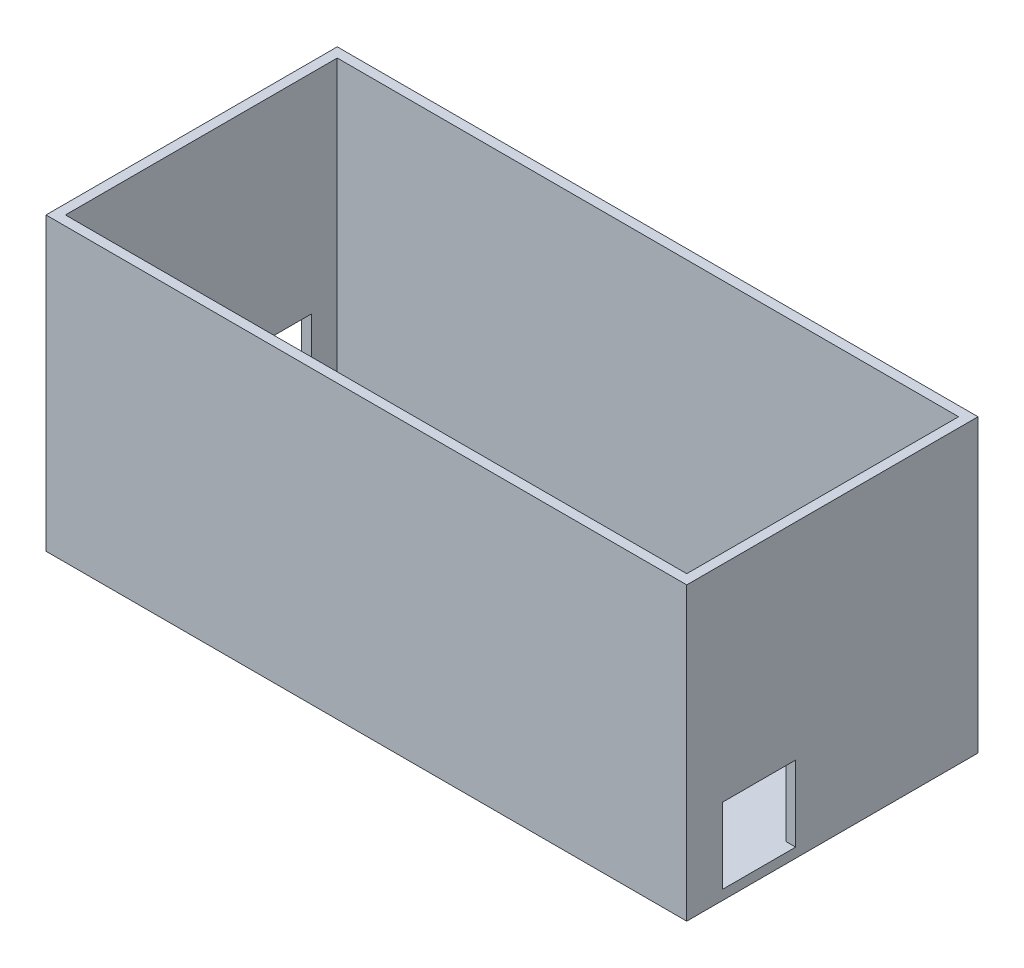
from build123d import *

# Parameters (mm, degrees)
ESQUISSE1_W             = 132
ESQUISSE1_H             = 60
BOSS_EXTRU_1_DEPTH      = 60
COQUE1_T                = -2
ESQUISSE2_W             = 15.270123606
ESQUISSE2_H             = 15.006197758
ENL_V_MAT_EXTRU_3_DEPTH = 150
ESQUISSE3_W             = 15.1141578
ESQUISSE3_H             = 15.542141472
ENL_V_MAT_EXTRU_4_DEPTH = 150


with BuildPart() as part:
    # Esquisse1 → Boss.-Extru.1 (new body)
    with BuildSketch(Plane(origin=(0, 0, 0), x_dir=(1, 0, 0), z_dir=(0, 1, 0))):
        with Locations((66, 30)):
            Rectangle(ESQUISSE1_W, ESQUISSE1_H)
    extrude(amount=BOSS_EXTRU_1_DEPTH)

    # Coque1
    coque1_openings = [part.faces().sort_by_distance(p)[0] for p in [
        (66, 60, -30),
    ]]
    offset(amount=COQUE1_T, openings=coque1_openings, kind=Kind.INTERSECTION)

    # Esquisse2 → Enlèv. mat.-Extru.3 (cut)
    with BuildSketch(Plane(origin=(2, 0, 0), x_dir=(0, 0, -1), z_dir=(1, 0, 0))):
        with Locations((45.027247918, 9.503098879)):
            Rectangle(ESQUISSE2_W, ESQUISSE2_H)
    extrude(amount=-ENL_V_MAT_EXTRU_3_DEPTH, mode=Mode.SUBTRACT)

    # Esquisse3 → Enlèv. mat.-Extru.4 (cut)
    with BuildSketch(Plane.ZY.offset(-130)):
        with Locations((-14.874699742, 9.771070736)):
            Rectangle(ESQUISSE3_W, ESQUISSE3_H)
    extrude(amount=-ENL_V_MAT_EXTRU_4_DEPTH, mode=Mode.SUBTRACT)


solid = part.part
